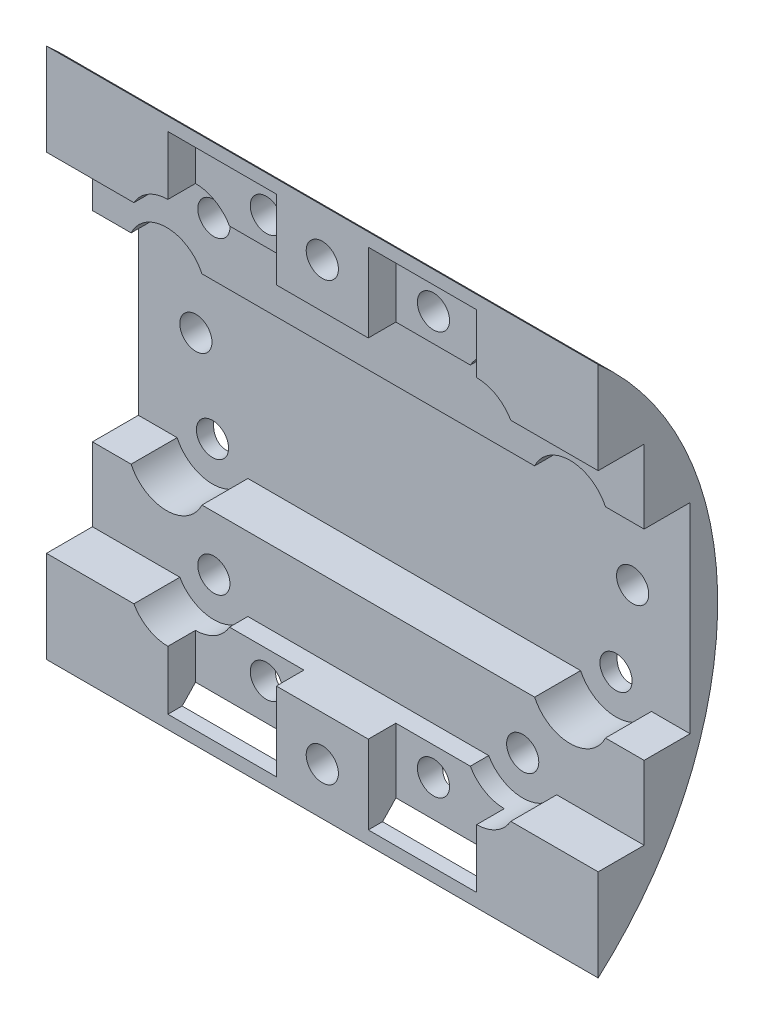
from build123d import *

# Parameters (mm, degrees)
BOSS_EXTRUDE2_DEPTH      = 30
BOSS_EXTRUDE2_DEPTH_BACK = 30
SKETCH2_R                = 1.75
CUT_EXTRUDE3_DEPTH       = 5.4
CUT_EXTRUDE3_DEPTH_BACK  = 9.6
CUT_EXTRUDE4_DEPTH       = 11.0000001
CUT_EXTRUDE5_START       = 5
SKETCH4_3_R              = 4.25
SKETCH4_3_R_2            = 1.75
CUT_EXTRUDE5_DEPTH       = 6.0000001
SKETCH5_R                = 1.75
CUT_EXTRUDE6_DEPTH       = 3


with BuildPart() as part:
    # Sketch3 → Boss-Extrude2 (new body, two sides)
    with BuildSketch(Plane(origin=(0, 0, 0), x_dir=(0, 0, -1), z_dir=(1, 0, 0))) as boss_extrude2_sk:
        with BuildLine():
            ThreePointArc((8.6, 0), (5.20028409, 15.839823231), (-4.4, 28.889444439))
            Line((-4.4, 28.889444439), (-4.4, 18.889444439))
            Line((-4.4, 18.889444439), (0.6, 18.889444439))
            Line((0.6, 18.889444439), (0.6, 10.889444439))
            Line((0.6, 10.889444439), (5.6, 10.889444439))
            Line((5.6, 10.889444439), (5.6, -10.889444439))
            Line((5.6, -10.889444439), (0.6, -10.889444439))
            Line((0.6, -10.889444439), (0.6, -18.889444439))
            Line((0.6, -18.889444439), (-4.4, -18.889444439))
            Line((-4.4, -18.889444439), (-4.4, -28.889444439))
            ThreePointArc((-4.4, -28.889444439), (5.20028409, -15.839823231), (8.6, 0))
        make_face()
    extrude(amount=BOSS_EXTRUDE2_DEPTH)
    extrude(boss_extrude2_sk.sketch, amount=-BOSS_EXTRUDE2_DEPTH_BACK)

    # Sketch2 → Cut-Extrude3 (cut, two sides)
    with BuildSketch(Plane.XY) as cut_extrude3_sk:
        with Locations((0, 23.75)):
            Circle(SKETCH2_R)
        with Locations((9.088731519, 21.942138897)):
            Circle(SKETCH2_R)
        with Locations((16.793786053, 16.793786053)):
            Circle(SKETCH2_R)
        with Locations((21.942138897, 9.088731519)):
            Circle(SKETCH2_R)
        with Locations((23.75, 0)):
            Circle(SKETCH2_R)
        with Locations((21.942138897, -9.088731519)):
            Circle(SKETCH2_R)
        with Locations((16.793786053, -16.793786053)):
            Circle(SKETCH2_R)
        with Locations((9.088731519, -21.942138897)):
            Circle(SKETCH2_R)
        with Locations((0, -23.75)):
            Circle(SKETCH2_R)
        with Locations((-9.088731519, -21.942138897)):
            Circle(SKETCH2_R)
        with Locations((-16.793786053, -16.793786053)):
            Circle(SKETCH2_R)
        with Locations((-21.942138897, -9.088731519)):
            Circle(SKETCH2_R)
        with Locations((-23.75, 0)):
            Circle(SKETCH2_R)
        with Locations((-21.942138897, 9.088731519)):
            Circle(SKETCH2_R)
        with Locations((-16.793786053, 16.793786053)):
            Circle(SKETCH2_R)
        with Locations((-9.088731519, 21.942138897)):
            Circle(SKETCH2_R)
    extrude(amount=CUT_EXTRUDE3_DEPTH, mode=Mode.SUBTRACT)
    extrude(cut_extrude3_sk.sketch, amount=-CUT_EXTRUDE3_DEPTH_BACK, mode=Mode.SUBTRACT)

    # Sketch4 → Cut-Extrude4 (cut, through all)
    with BuildSketch(Plane.XY.offset(-5.6)):
        with BuildLine():
            Line((-25.791805503, 10.889444439), (-18.092472291, 10.889444439))
            ThreePointArc((-18.092472291, 10.889444439), (-21.942138897, 13.338731519), (-25.791805503, 10.889444439))
        make_face()
        with BuildLine():
            Line((-18.092472291, -10.889444439), (-25.791805503, -10.889444439))
            ThreePointArc((-25.791805503, -10.889444439), (-21.942138897, -13.338731519), (-18.092472291, -10.889444439))
        make_face()
        with BuildLine():
            Line((25.791805503, -10.889444439), (18.092472291, -10.889444439))
            ThreePointArc((18.092472291, -10.889444439), (21.942138897, -13.338731519), (25.791805503, -10.889444439))
        make_face()
        with BuildLine():
            ThreePointArc((25.791805503, 10.889444439), (21.942138897, 13.338731519), (18.092472291, 10.889444439))
            Line((18.092472291, 10.889444439), (25.791805503, 10.889444439))
        make_face()
    extrude(amount=CUT_EXTRUDE4_DEPTH, mode=Mode.SUBTRACT)

    # Sketch4_3 → Cut-Extrude5 (cut, through all)
    with BuildSketch(Plane.XY.offset(-5.6).offset(CUT_EXTRUDE5_START)):
        with Locations((-16.793786053, -16.793786053)):
            Circle(SKETCH4_3_R)
        with Locations((-16.793786053, -16.793786053)):
            Circle(SKETCH4_3_R_2, mode=Mode.SUBTRACT)
        with Locations((16.793786053, -16.793786053)):
            Circle(SKETCH4_3_R)
        with Locations((16.793786053, -16.793786053)):
            Circle(SKETCH4_3_R_2, mode=Mode.SUBTRACT)
        with Locations((-16.793786053, 16.793786053)):
            Circle(SKETCH4_3_R)
        with Locations((-16.793786053, 16.793786053)):
            Circle(SKETCH4_3_R_2, mode=Mode.SUBTRACT)
        with Locations((16.793786053, 16.793786053)):
            Circle(SKETCH4_3_R)
        with Locations((16.793786053, 16.793786053)):
            Circle(SKETCH4_3_R_2, mode=Mode.SUBTRACT)
    extrude(amount=CUT_EXTRUDE5_DEPTH, mode=Mode.SUBTRACT)

    # Sketch5 → Cut-Extrude6 (cut)
    with BuildSketch(Plane.XY.offset(4.4)):
        with BuildLine():
            Line((-16.793786053, 27.442138897), (-16.793786053, 21.043786053))
            ThreePointArc((-16.793786053, 21.043786053), (-14.654165542, 20.465914056), (-13.096392927, 18.889444439))
            Line((-13.096392927, 18.889444439), (-5, 18.889444439))
            Line((-5, 18.889444439), (-5, 27.442138897))
            Line((-5, 27.442138897), (-16.793786053, 27.442138897))
        make_face()
        with BuildLine():
            Line((16.793786053, 27.442138897), (5, 27.442138897))
            Line((5, 27.442138897), (5, 18.889444439))
            Line((5, 18.889444439), (13.096392927, 18.889444439))
            ThreePointArc((13.096392927, 18.889444439), (14.654165542, 20.465914056), (16.793786053, 21.043786053))
            Line((16.793786053, 21.043786053), (16.793786053, 27.442138897))
        make_face()
        with BuildLine():
            Line((13.096392927, -18.889444439), (5, -18.889444439))
            Line((5, -18.889444439), (5, -27.442138897))
            Line((5, -27.442138897), (16.793786053, -27.442138897))
            Line((16.793786053, -27.442138897), (16.793786053, -21.043786053))
            ThreePointArc((16.793786053, -21.043786053), (14.654165542, -20.465914056), (13.096392927, -18.889444439))
        make_face()
        with Locations((9.088731519, -21.942138897)):
            Circle(SKETCH5_R, mode=Mode.SUBTRACT)
        with BuildLine():
            Line((-5, -27.442138897), (-5, -18.889444439))
            Line((-5, -18.889444439), (-13.096392927, -18.889444439))
            ThreePointArc((-13.096392927, -18.889444439), (-14.654165542, -20.465914056), (-16.793786053, -21.043786053))
            Line((-16.793786053, -21.043786053), (-16.793786053, -27.442138897))
            Line((-16.793786053, -27.442138897), (-5, -27.442138897))
        make_face()
        with Locations((-9.088731519, -21.942138897)):
            Circle(SKETCH5_R, mode=Mode.SUBTRACT)
    extrude(amount=-CUT_EXTRUDE6_DEPTH, mode=Mode.SUBTRACT)


solid = part.part
